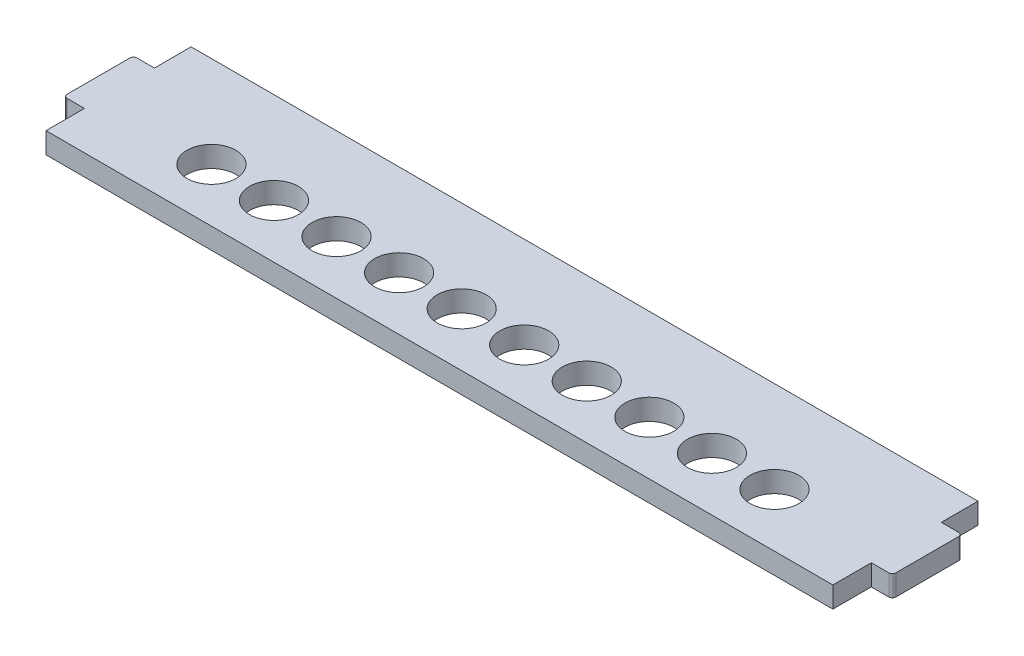
from build123d import *

# Parameters (mm, degrees)
SKETCH_1_R      = 3.5
EXTRUDE_1_DEPTH = 3
FILLET_1_R      = 0.5


with BuildPart() as part:
    # Эскиз1 → Бобышка-Вытянуть1 (new body)
    with BuildSketch(Plane(origin=(0, 0, 0), x_dir=(1, 0, 0), z_dir=(0, 1, 0))):
        Polygon((-56.25, -20.75), (56.25, -20.75), (56.25, -15.25), (59.25, -15.25), (59.25, -5.25), (56.25, -5.25), (56.25, 0), (-56.25, 0), (-56.25, -5.25), (-59.25, -5.25), (-59.25, -15.25), (-56.25, -15.25), align=None)
        with Locations((-40.25, -13.1)):
            Circle(SKETCH_1_R, mode=Mode.SUBTRACT)
        with Locations((-31.305555556, -13.1)):
            Circle(SKETCH_1_R, mode=Mode.SUBTRACT)
        with Locations((-22.361111111, -13.1)):
            Circle(SKETCH_1_R, mode=Mode.SUBTRACT)
        with Locations((-13.416666667, -13.1)):
            Circle(SKETCH_1_R, mode=Mode.SUBTRACT)
        with Locations((-4.472222222, -13.1)):
            Circle(SKETCH_1_R, mode=Mode.SUBTRACT)
        with Locations((4.472222222, -13.1)):
            Circle(SKETCH_1_R, mode=Mode.SUBTRACT)
        with Locations((13.416666667, -13.1)):
            Circle(SKETCH_1_R, mode=Mode.SUBTRACT)
        with Locations((22.361111111, -13.1)):
            Circle(SKETCH_1_R, mode=Mode.SUBTRACT)
        with Locations((31.305555556, -13.1)):
            Circle(SKETCH_1_R, mode=Mode.SUBTRACT)
        with Locations((40.25, -13.1)):
            Circle(SKETCH_1_R, mode=Mode.SUBTRACT)
    extrude(amount=EXTRUDE_1_DEPTH)

    # Скругление1
    fillet_1_edges = [part.edges().sort_by_distance(p)[0] for p in [
        (-59.25, 1.5, 15.25),
        (-59.25, 1.5, 5.25),
        (59.25, 1.5, 5.25),
        (59.25, 1.5, 15.25),
    ]]
    fillet(fillet_1_edges, radius=FILLET_1_R)


solid = part.part
